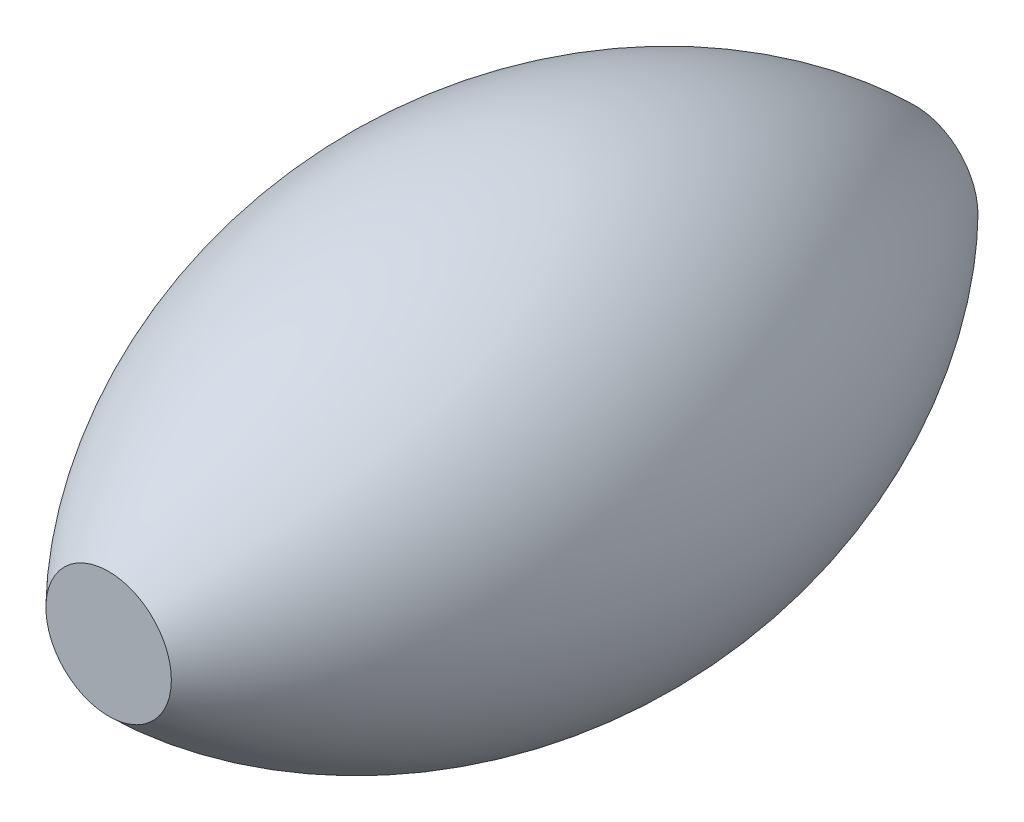
from build123d import *


with BuildPart() as part:
    # Sketch1 → Revolve1 (revolve)
    with BuildSketch(Plane(origin=(0, 0, 0), x_dir=(0, 0, -1), z_dir=(1, 0, 0))):
        with BuildLine():
            Line((-112.5, 17.5), (-112.5, 0))
            Line((-112.5, 0), (112.5, 0))
            Line((112.5, 0), (112.5, 17.5))
            ThreePointArc((112.5, 17.5), (0, 63.5), (-112.5, 17.5))
        make_face()
    revolve(axis=Axis((0, 0, 112.5), (0, 0, -1)))


solid = part.part
